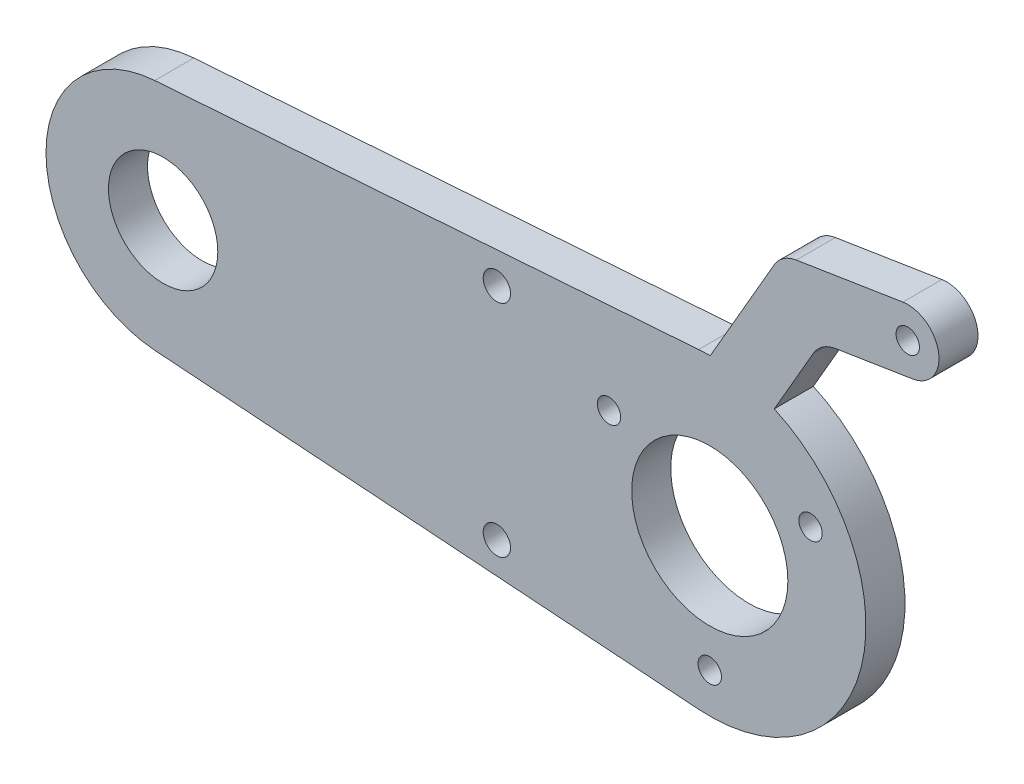
from build123d import *

# Parameters (mm, degrees)
SKETCH1_R           = 7
SKETCH1_R_2         = 10
SKETCH1_R_3         = 1.5
SKETCH1_R_4         = 1.75
BOSS_EXTRUDE1_DEPTH = 5


with BuildPart() as part:
    # Sketch1 → Boss-Extrude1 (new body)
    with BuildSketch(Plane.XY):
        with BuildLine():
            Line((-71.071428571, 14.961685761), (-1.428571429, 19.948914348))
            ThreePointArc((-1.428571429, 19.948914348), (-0.686118829, 19.988227559), (0.057281956, 19.999917969))
            Line((0.057281956, 19.999917969), (8.242983117, 34.177968276))
            ThreePointArc((8.242983117, 34.177968276), (9.441459784, 35.47447303), (11.081346872, 36.128721638))
            Line((11.081346872, 36.128721638), (24.727055657, 38.289989587))
            ThreePointArc((24.727055657, 38.289989587), (29.30354688, 34.964974085), (25.978531377, 30.388482862))
            Line((25.978531377, 30.388482862), (16.101647971, 28.824138212))
            ThreePointArc((16.101647971, 28.824138212), (14.461760884, 28.169889604), (13.263284216, 26.873384849))
            Line((13.263284216, 26.873384849), (8.263284216, 18.213130812))
            ThreePointArc((8.263284216, 18.213130812), (19.384626574, -4.923032864), (-1.428571429, -19.948914348))
            Line((-1.428571429, -19.948914348), (-71.071428571, -14.961685761))
            ThreePointArc((-71.071428571, -14.961685761), (-85, 0), (-71.071428571, 14.961685761))
        make_face()
        with Locations((-70, 0)):
            Circle(SKETCH1_R, mode=Mode.SUBTRACT)
        Circle(SKETCH1_R_2, mode=Mode.SUBTRACT)
        with Locations((-12.903778516, 7.45)):
            Circle(SKETCH1_R_3, mode=Mode.SUBTRACT)
        with Locations((0, -14.9)):
            Circle(SKETCH1_R_3, mode=Mode.SUBTRACT)
        with Locations((-27.262321561, 14.088677781)):
            Circle(SKETCH1_R_4, mode=Mode.SUBTRACT)
        with Locations((-27.262321561, -14.088677781)):
            Circle(SKETCH1_R_4, mode=Mode.SUBTRACT)
        with Locations((12.903778516, 7.45)):
            Circle(SKETCH1_R_3, mode=Mode.SUBTRACT)
        with Locations((25.352793517, 34.339236225)):
            Circle(SKETCH1_R_3, mode=Mode.SUBTRACT)
    extrude(amount=BOSS_EXTRUDE1_DEPTH)


with BuildPart() as part_1:
    # Body-Move/Copy1: moved
    add(part.part.moved(Location((0, 0, -5))))


solid = part_1.part
